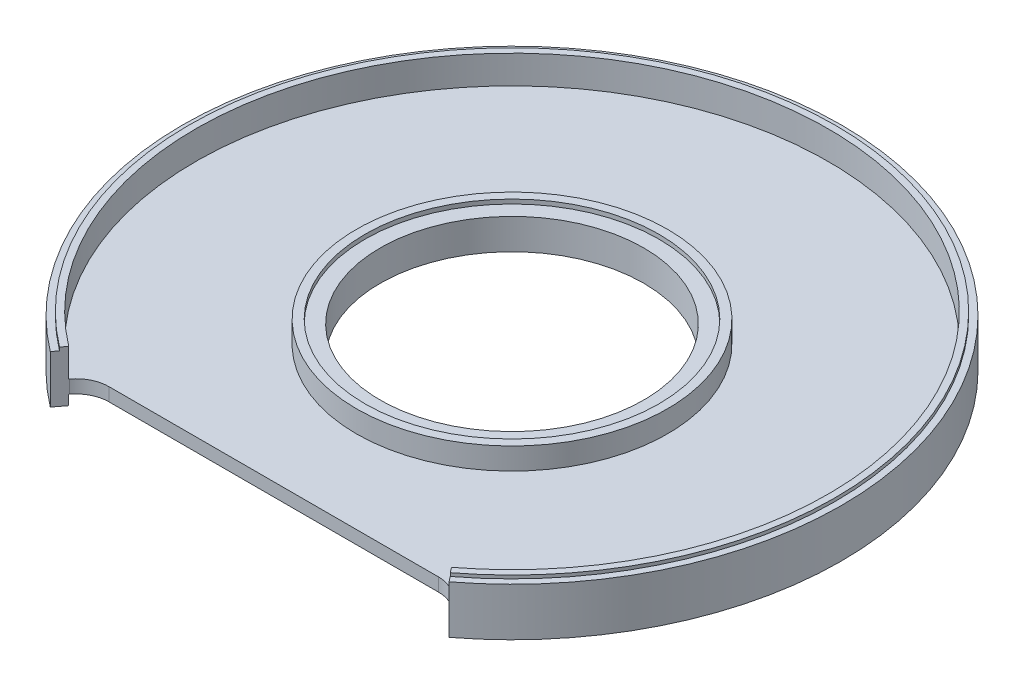
from build123d import *

# Parameters (mm, degrees)
SKETCH2_W               = 1
SKETCH2_H               = 0.5
SKETCH2_W_2             = 1.3
SKETCH2_H_2             = 0.65
CUT_EXTRUDE2_DEPTH      = 5.15
CUT_EXTRUDE2_DEPTH_BACK = 4.65


with BuildPart() as part:
    # Sketch2 → Revolve1 (revolve)
    with BuildSketch(Plane(origin=(0, 0, 0), x_dir=(0, 0, -1), z_dir=(1, 0, 0))):
        Polygon((-49, 3.65), (-50, 3.65), (-50, -3.65), (-48, -3.65), (-48, -2.15), (-48, -0.15), (-48, 3.65), align=None)
        with Locations((-48.5, 3.9)):
            Rectangle(SKETCH2_W, SKETCH2_H)
        Polygon((-23.6, -0.15), (-48, -0.15), (-48, -2.15), (-20, -2.15), (-20, -0.15), align=None)
        Polygon((-23.6, 2.5), (-23.6, -0.15), (-20, -0.15), (-20, 2.5), (-22.3, 2.5), align=None)
        with Locations((-22.95, 2.825)):
            Rectangle(SKETCH2_W_2, SKETCH2_H_2)
    revolve(axis=Axis((0, 0, 0), (0, 1, 0)))

    # Sketch3 → Cut-Extrude2 (cut, two sides)
    with BuildSketch(Plane(origin=(0, 0, 0), x_dir=(1, 0, 0), z_dir=(0, 1, 0))) as cut_extrude2_sk:
        with BuildLine():
            Line((-182.0491461, -239.559631704), (-30.252223805, -39.809583706))
            Line((-30.252223805, -39.809583706), (-28.980936876, -38.136693234))
            ThreePointArc((-28.980936876, -38.136693234), (-27.221907589, -36.68275573), (-25, -36.1619439))
            Line((-25, -36.1619439), (25, -36.1619439))
            ThreePointArc((25, -36.1619439), (27.2219242, -36.682763969), (28.980959314, -38.13672276))
            Line((28.980959314, -38.13672276), (30.252211397, -39.809593135))
            Line((30.252211397, -39.809593135), (182.047652189, -239.56076697))
            Line((182.047652189, -239.56076697), (182.046087664, -741.32719587))
            Line((182.046087664, -741.32719587), (-182.050710625, -741.326060604))
            Line((-182.050710625, -741.326060604), (-182.0491461, -239.559631704))
        make_face()
    extrude(amount=CUT_EXTRUDE2_DEPTH, mode=Mode.SUBTRACT)
    extrude(cut_extrude2_sk.sketch, amount=-CUT_EXTRUDE2_DEPTH_BACK, mode=Mode.SUBTRACT)


solid = part.part
